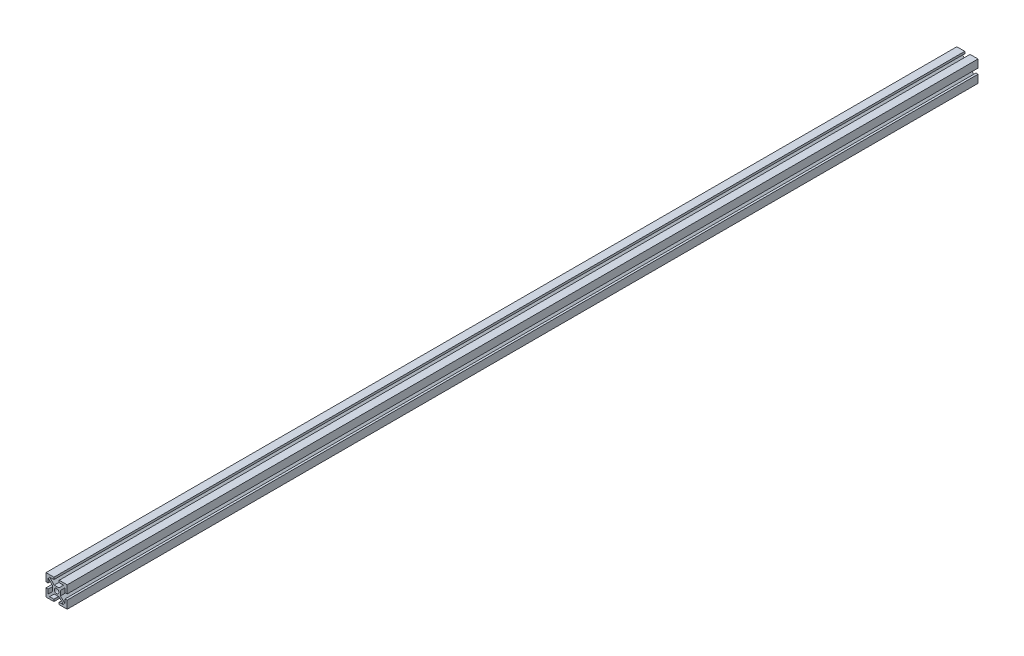
from build123d import *

# Parameters (mm, degrees)
ESQUISSE1_R        = 2.15
BOSS_EXTRU_1_DEPTH = 860


with BuildPart() as part:
    # Esquisse1 → Boss.-Extru.1 (new body)
    with BuildSketch(Plane.XY):
        Polygon((-2.5, 10), (-10, 10), (-10, 2.5), (-8, 2.5), (-8, 6.585786438), (-3.65, 2.235786438), (-3.65, -2.235786438), (-8, -6.585786438), (-8, -2.5), (-10, -2.5), (-10, -10), (-2.5, -10), (-2.5, -8), (-6.585786438, -8), (-2.235786438, -3.65), (2.235786438, -3.65), (6.585786438, -8), (2.5, -8), (2.5, -10), (10, -10), (10, -2.5), (8, -2.5), (8, -6.585786438), (3.65, -2.235786438), (3.65, 2.235786438), (8, 6.585786438), (8, 2.5), (10, 2.5), (10, 10), (2.5, 10), (2.5, 8), (6.585786438, 8), (2.235786438, 3.65), (-2.235786438, 3.65), (-6.585786438, 8), (-2.5, 8), align=None)
        Circle(ESQUISSE1_R, mode=Mode.SUBTRACT)
    extrude(amount=BOSS_EXTRU_1_DEPTH)


solid = part.part
